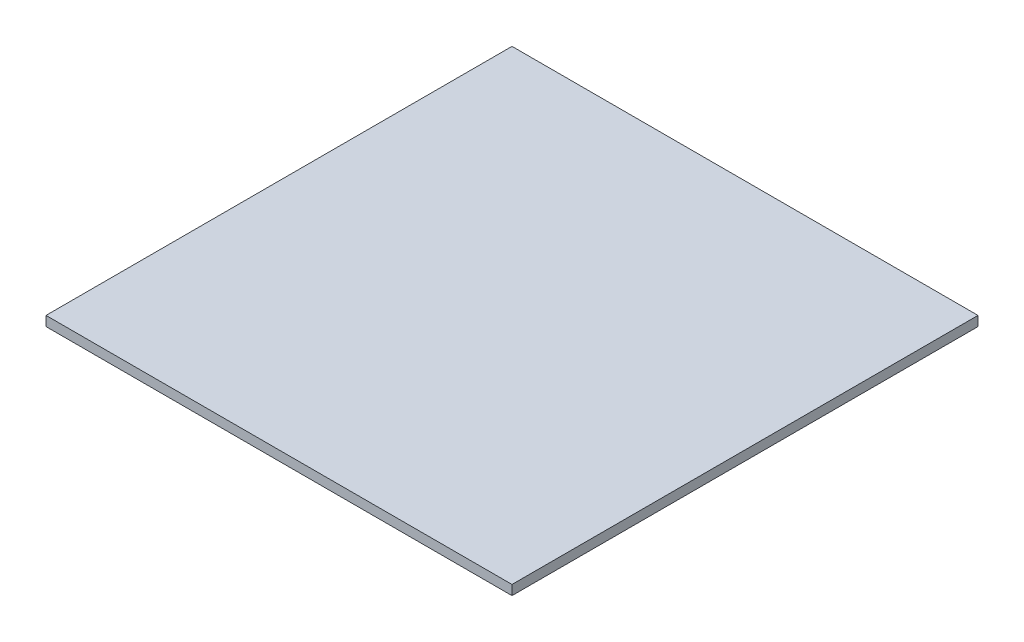
from build123d import *

# Parameters (mm, degrees)
SKETCH1_W           = 609.6
SKETCH1_H           = 609.6
BOSS_EXTRUDE1_DEPTH = 12.7


with BuildPart() as part:
    # Sketch1 → Boss-Extrude1 (new body)
    with BuildSketch(Plane(origin=(0, 0, 0), x_dir=(1, 0, 0), z_dir=(0, 1, 0))):
        Rectangle(SKETCH1_W, SKETCH1_H)
    extrude(amount=BOSS_EXTRUDE1_DEPTH)


solid = part.part
